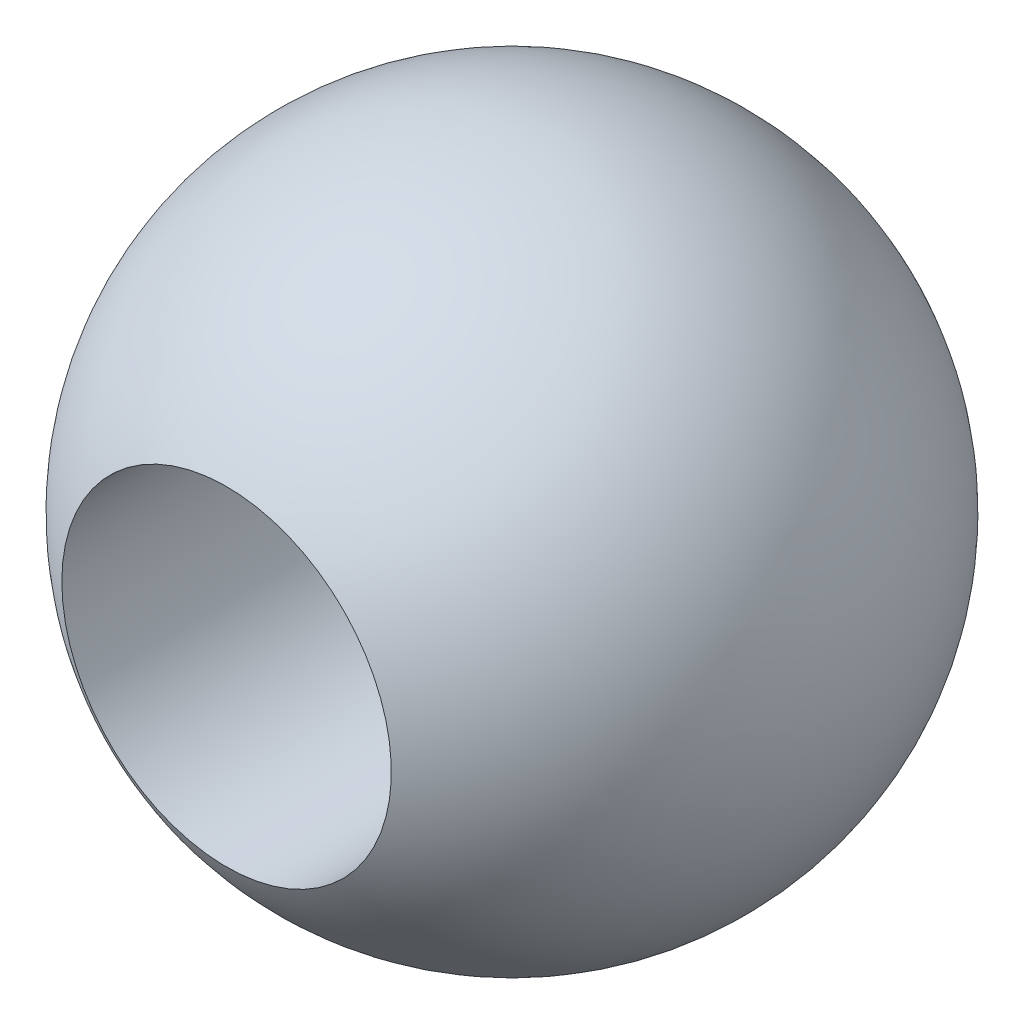
from build123d import *

# Parameters (mm, degrees)
CUT_EXTRUDE1_DEPTH      = 6.499261314
CUT_EXTRUDE1_DEPTH_BACK = 6.499261314
SKETCH1_3_R             = 1.5875


with BuildPart() as part:
    # Sketch1 → Revolve1 (revolve)
    with BuildSketch(Plane.XY):
        with BuildLine():
            ThreePointArc((0, 3.175), (-3.175, 0), (0, -3.175))
            Line((0, -3.175), (0, -1.5875))
            ThreePointArc((0, -1.5875), (-1.5875, 0), (0, 1.5875))
            Line((0, 1.5875), (0, 3.175))
        make_face()
    revolve(axis=Axis((0, -59.59994195, 0), (0, 1, 0)))

    # Sketch1_3 → Cut-Extrude1 (cut, two sides: drawn at the far end of the back side and taken through both)
    with BuildSketch(Plane.XY.offset(-CUT_EXTRUDE1_DEPTH_BACK)):
        Circle(SKETCH1_3_R)
    extrude(amount=CUT_EXTRUDE1_DEPTH + CUT_EXTRUDE1_DEPTH_BACK, mode=Mode.SUBTRACT)


solid = part.part
